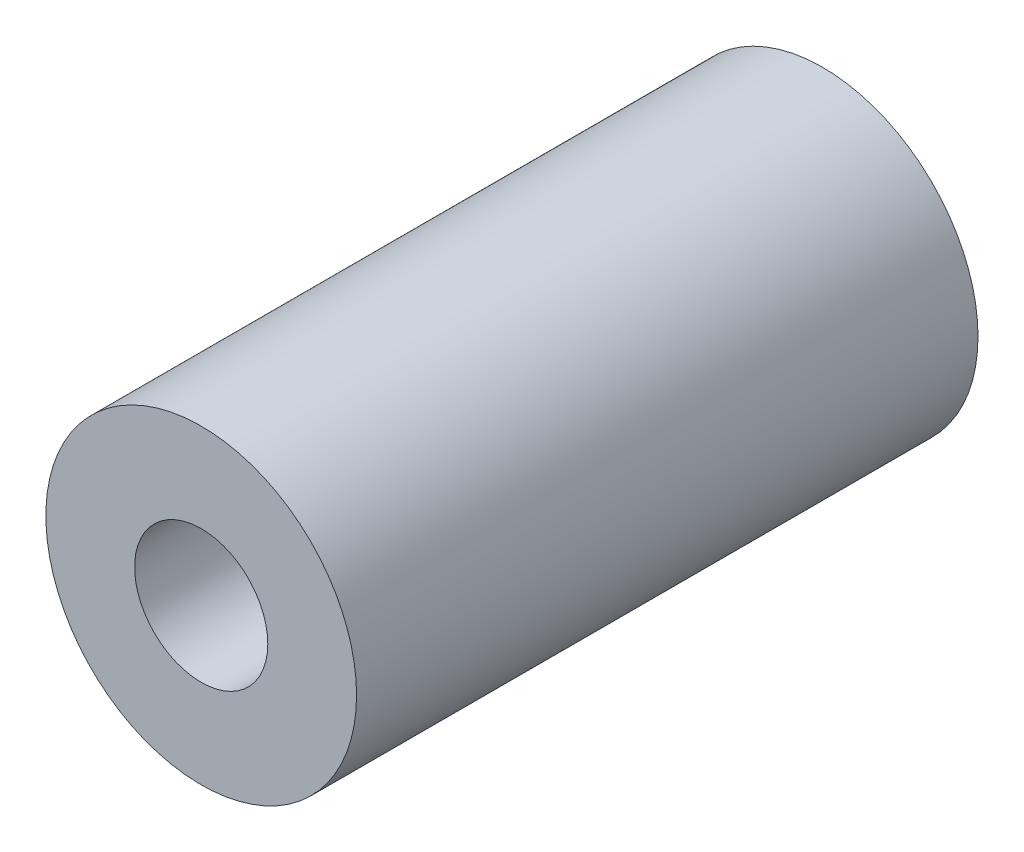
from build123d import *

# Parameters (mm, degrees)
SKETCH1_R           = 11.1125
SKETCH1_R_2         = 4.7625
BOSS_EXTRUDE1_DEPTH = 44.45


with BuildPart() as part:
    # Sketch1 → Boss-Extrude1 (new body)
    with BuildSketch(Plane.XY):
        Circle(SKETCH1_R)
        Circle(SKETCH1_R_2, mode=Mode.SUBTRACT)
    extrude(amount=BOSS_EXTRUDE1_DEPTH)


solid = part.part
